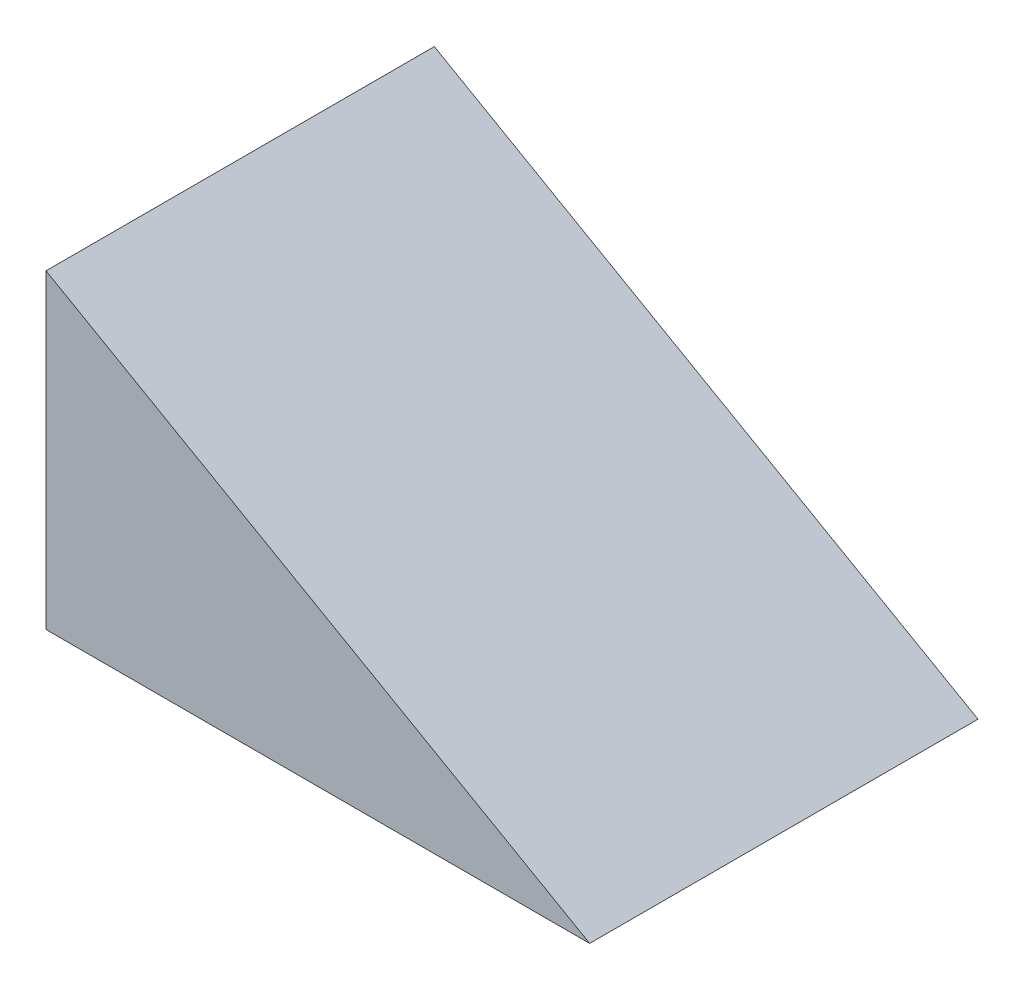
from build123d import *

# Parameters (mm, degrees)
BOSS_EXTRUDE2_DEPTH = 50


with BuildPart() as part:
    # Sketch1 → Boss-Extrude2 (new body)
    with BuildSketch(Plane.XY):
        Polygon((0, 0), (70, 0), (0, 40), align=None)
    extrude(amount=BOSS_EXTRUDE2_DEPTH)


solid = part.part
